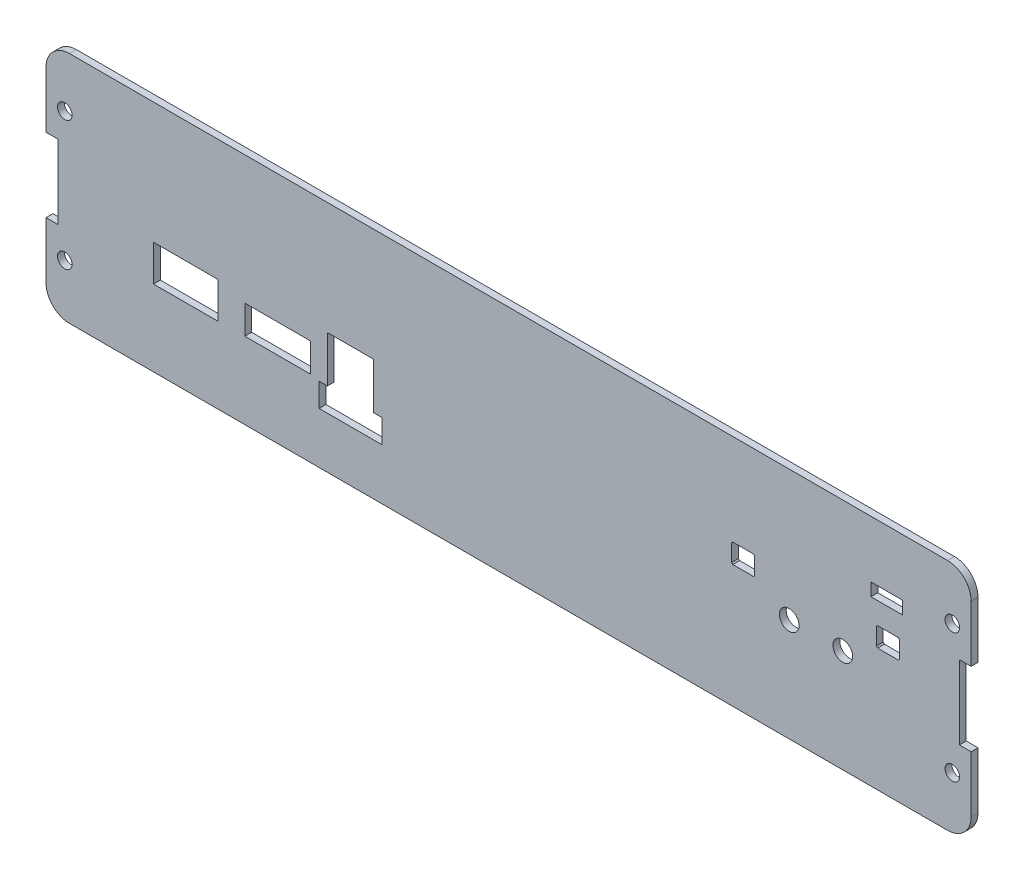
from build123d import *

# Parameters (mm, degrees)
MAINBODY_DEPTH    = 1.8542
SKETCH3_R         = 1.9685
MOUNTHOLES_DEPTH  = 129.907885308
PANELCUTOUT_REACH = 130.908
SKETCH4_R         = 2.667
SKETCH4_W         = 8.534035503
SKETCH4_H         = 3.447371256
SKETCH4_W_2       = 17.373674213
SKETCH4_H_2       = 9.779
SKETCH4_W_3       = 17.808
SKETCH4_H_3       = 7.758


with BuildPart() as part:
    # Sketch2 → MainBody (new body)
    with BuildSketch(Plane.XY):
        with BuildLine():
            Line((118.618, 31.5722), (-118.618, 31.5722))
            ThreePointArc((-118.618, 31.5722), (-123.108128061, 29.712328061), (-124.968, 25.2222))
            Line((-124.968, 25.2222), (-124.968, 9.9822))
            Line((-124.968, 9.9822), (-121.793, 9.9822))
            Line((-121.793, 9.9822), (-121.793, -9.9822))
            Line((-121.793, -9.9822), (-124.968, -9.9822))
            Line((-124.968, -9.9822), (-124.968, -25.2222))
            ThreePointArc((-124.968, -25.2222), (-123.108128061, -29.712328061), (-118.618, -31.5722))
            Line((-118.618, -31.5722), (118.618, -31.5722))
            ThreePointArc((118.618, -31.5722), (123.108128061, -29.712328061), (124.968, -25.2222))
            Line((124.968, -25.2222), (124.968, -9.9822))
            Line((124.968, -9.9822), (121.793, -9.9822))
            Line((121.793, -9.9822), (121.793, 9.9822))
            Line((121.793, 9.9822), (124.968, 9.9822))
            Line((124.968, 9.9822), (124.968, 25.2222))
            ThreePointArc((124.968, 25.2222), (123.108128061, 29.712328061), (118.618, 31.5722))
        make_face()
    extrude(amount=MAINBODY_DEPTH)

    # Sketch3 → MountHoles (cut, through all)
    with BuildSketch(Plane.XY.offset(1.8542)):
        with Locations((-119.888, 17.4625)):
            Circle(SKETCH3_R)
        with Locations((119.888, 17.4625)):
            Circle(SKETCH3_R)
        with Locations((119.888, -17.4625)):
            Circle(SKETCH3_R)
        with Locations((-119.888, -17.4625)):
            Circle(SKETCH3_R)
    extrude(amount=-MOUNTHOLES_DEPTH, mode=Mode.SUBTRACT)

    # Sketch4 → PanelCutout (cut, up to next)
    with BuildSketch(Plane.XY.offset(1.8542), mode=Mode.PRIVATE) as panelcutout_sk1:
        with Locations((90.297, -3.729450093)):
            Circle(SKETCH4_R)
    panelcutout_tool1 = extrude(panelcutout_sk1.sketch, amount=-PANELCUTOUT_REACH, mode=Mode.PRIVATE) & part.part
    # Sketch4 → PanelCutout (cut, up to next)
    with BuildSketch(Plane.XY.offset(1.8542), mode=Mode.PRIVATE) as panelcutout_sk2:
        with Locations((75.819, -3.729450093)):
            Circle(SKETCH4_R)
    panelcutout_tool2 = extrude(panelcutout_sk2.sketch, amount=-PANELCUTOUT_REACH, mode=Mode.PRIVATE) & part.part
    # Sketch4 → PanelCutout (cut, up to next)
    with BuildSketch(Plane.XY.offset(1.8542), mode=Mode.PRIVATE) as panelcutout_sk3:
        with Locations((102.1588002, 14.470550015)):
            Rectangle(SKETCH4_W, SKETCH4_H)
    panelcutout_tool3 = extrude(panelcutout_sk3.sketch, amount=-PANELCUTOUT_REACH, mode=Mode.PRIVATE) & part.part
    # Sketch4 → PanelCutout (cut, up to next)
    with BuildSketch(Plane.XY.offset(1.8542), mode=Mode.PRIVATE) as panelcutout_sk4:
        with Locations((-87.246762894, -6.11895)):
            Rectangle(SKETCH4_W_2, SKETCH4_H_2)
    panelcutout_tool4 = extrude(panelcutout_sk4.sketch, amount=-PANELCUTOUT_REACH, mode=Mode.PRIVATE) & part.part
    # Sketch4 → PanelCutout (cut, up to next)
    with BuildSketch(Plane.XY.offset(1.8542), mode=Mode.PRIVATE) as panelcutout_sk5:
        with Locations((-62.3548, -7.00245)):
            Rectangle(SKETCH4_W_3, SKETCH4_H_3)
    panelcutout_tool5 = extrude(panelcutout_sk5.sketch, amount=-PANELCUTOUT_REACH, mode=Mode.PRIVATE) & part.part
    # Sketch4 → PanelCutout (cut, up to next)
    with BuildSketch(Plane.XY.offset(1.8542), mode=Mode.PRIVATE) as panelcutout_sk6:
        Polygon((-36.424791576, -11.38945), (-36.424791576, 1.12655), (-48.968754151, 1.12655), (-48.968754151, -11.38945), (-51.1788, -11.38945), (-51.1788, -17.73945), (-34.1608, -17.73945), (-34.1608, -11.38945), align=None)
    panelcutout_tool6 = extrude(panelcutout_sk6.sketch, amount=-PANELCUTOUT_REACH, mode=Mode.PRIVATE) & part.part
    # Sketch4 → PanelCutout (cut, up to next)
    with BuildSketch(Plane.XY.offset(1.8542), mode=Mode.PRIVATE) as panelcutout_sk7:
        Polygon((60.2488, 6.547255322), (60.2488, 1.946245078), (60.577194878, 1.6178502), (66.168805122, 1.6178502), (66.4972, 1.946245078), (66.4972, 6.547255322), (66.168805122, 6.8756502), (60.577194878, 6.8756502), align=None)
    panelcutout_tool7 = extrude(panelcutout_sk7.sketch, amount=-PANELCUTOUT_REACH, mode=Mode.PRIVATE) & part.part
    # Sketch4 → PanelCutout (cut, up to next)
    with BuildSketch(Plane.XY.offset(1.8542), mode=Mode.PRIVATE) as panelcutout_sk8:
        Polygon((99.3648, 6.547255322), (99.3648, 1.946245078), (99.693194878, 1.6178502), (105.284805122, 1.6178502), (105.6132, 1.946245078), (105.6132, 6.547255322), (105.284805122, 6.8756502), (99.693194878, 6.8756502), align=None)
    panelcutout_tool8 = extrude(panelcutout_sk8.sketch, amount=-PANELCUTOUT_REACH, mode=Mode.PRIVATE) & part.part
    add(panelcutout_tool1.solids().sort_by_distance((90.297, -3.72945, 1.8542))[0], mode=Mode.SUBTRACT)
    add(panelcutout_tool2.solids().sort_by_distance((75.819, -3.72945, 1.8542))[0], mode=Mode.SUBTRACT)
    add(panelcutout_tool3.solids().sort_by_distance((102.1588, 14.47055, 1.8542))[0], mode=Mode.SUBTRACT)
    add(panelcutout_tool4.solids().sort_by_distance((-87.246763, -6.11895, 1.8542))[0], mode=Mode.SUBTRACT)
    add(panelcutout_tool5.solids().sort_by_distance((-62.3548, -7.00245, 1.8542))[0], mode=Mode.SUBTRACT)
    add(panelcutout_tool6.solids().sort_by_distance((-42.685776, -8.977195, 1.8542))[0], mode=Mode.SUBTRACT)
    add(panelcutout_tool7.solids().sort_by_distance((63.373, 4.24675, 1.8542))[0], mode=Mode.SUBTRACT)
    add(panelcutout_tool8.solids().sort_by_distance((102.489, 4.24675, 1.8542))[0], mode=Mode.SUBTRACT)


solid = part.part
